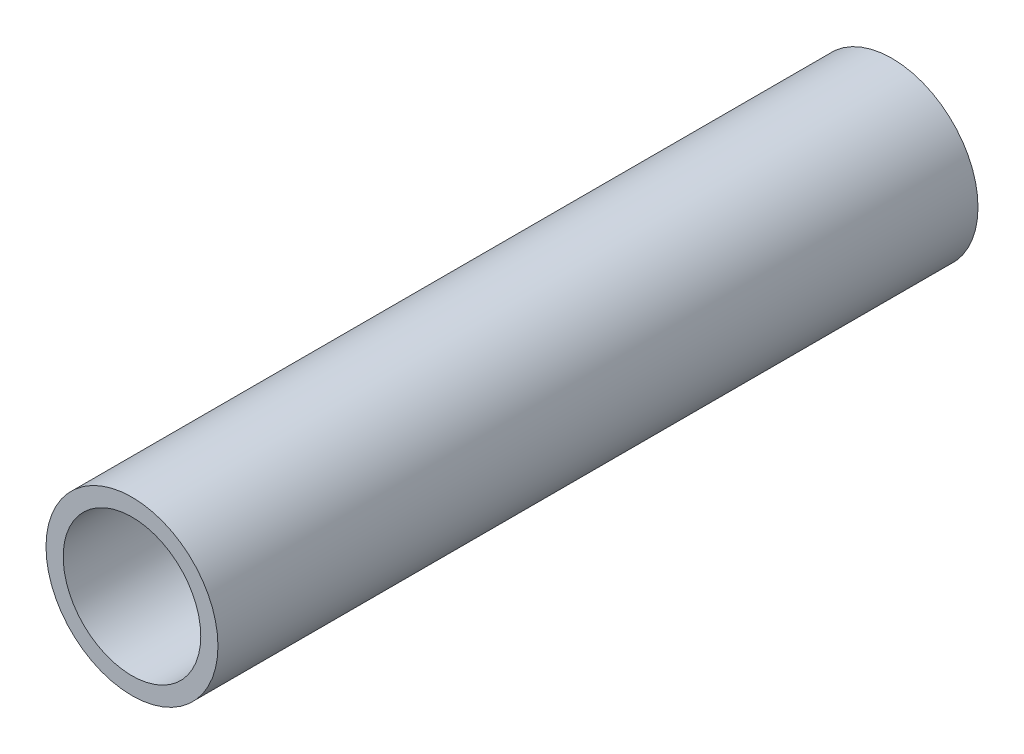
from build123d import *

# Parameters (mm, degrees)
SKETCH1_R           = 5
SKETCH1_R_2         = 4
BOSS_EXTRUDE1_DEPTH = 44.2


with BuildPart() as part:
    # Sketch1 → Boss-Extrude1 (new body)
    with BuildSketch(Plane.XY):
        Circle(SKETCH1_R)
        Circle(SKETCH1_R_2, mode=Mode.SUBTRACT)
    extrude(amount=BOSS_EXTRUDE1_DEPTH)


solid = part.part
